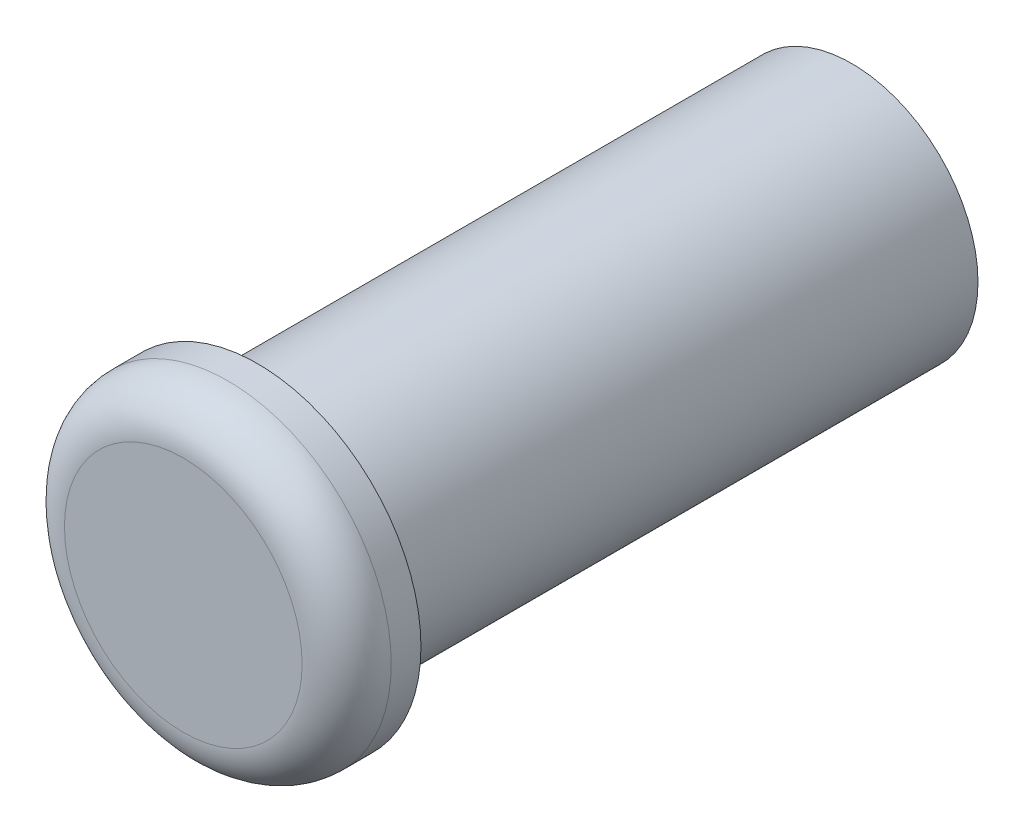
from build123d import *

# Parameters (mm, degrees)
SKETCH1_R           = 8.5
BOSS_EXTRUDE1_DEPTH = 40
SKETCH2_R           = 11
BOSS_EXTRUDE2_DEPTH = 5
FILLET1_R           = 3


with BuildPart() as part:
    # Sketch1 → Boss-Extrude1 (new body)
    with BuildSketch(Plane.XY):
        Circle(SKETCH1_R)
    extrude(amount=BOSS_EXTRUDE1_DEPTH)

    # Sketch2 → Boss-Extrude2 (add)
    with BuildSketch(Plane.XY.offset(40)):
        Circle(SKETCH2_R)
    extrude(amount=BOSS_EXTRUDE2_DEPTH)

    # Fillet1
    fillet1_edges = [part.edges().sort_by_distance(p)[0] for p in [
        (-11, 0, 45),
    ]]
    fillet(fillet1_edges, radius=FILLET1_R)


solid = part.part
